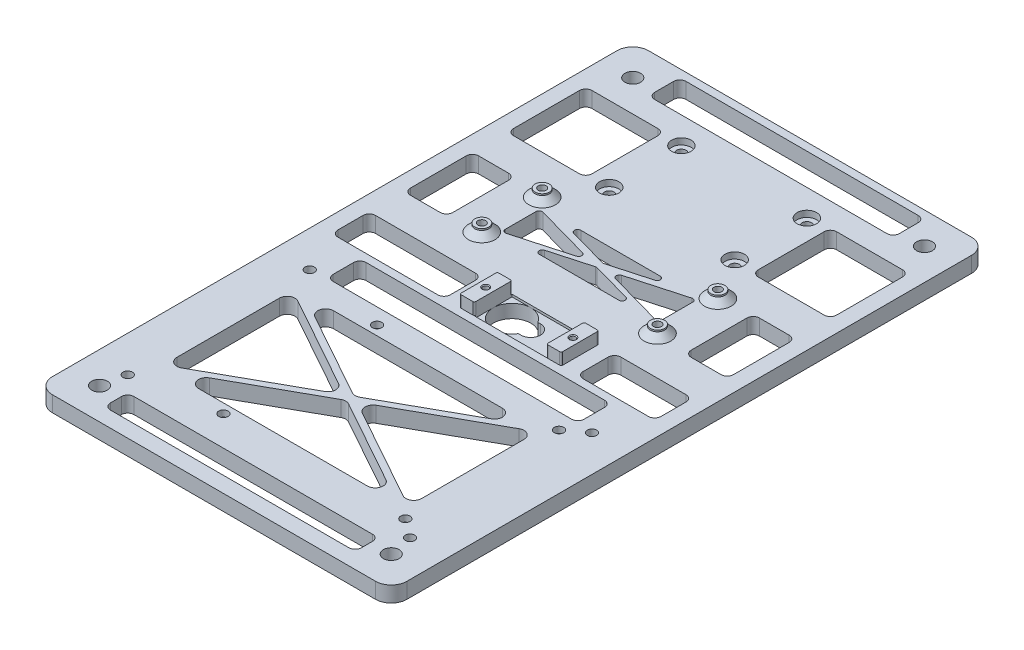
from build123d import *

# Parameters (mm, degrees)
SKETCH1_W           = 113
SKETCH1_H           = 190
SKETCH1_R           = 2.5
BOSS_EXTRUDE1_DEPTH = 5
FILLET1_R           = 5
SKETCH2_R           = 1.5
CUT_EXTRUDE1_DEPTH  = 10
SKETCH3_R           = 1.5
CUT_EXTRUDE2_DEPTH  = 10
CUT_EXTRUDE4_DEPTH  = 10
CUT_EXTRUDE16_DEPTH = 111.644701635
SKETCH22_W          = 23
SKETCH22_H          = 12
CUT_EXTRUDE17_DEPTH = 0.75
SKETCH23_W          = 4.675
SKETCH23_H          = 12
SKETCH23_R          = 0.875
BOSS_EXTRUDE5_DEPTH = 3.75
SKETCH24_R          = 0.875
CUT_EXTRUDE18_DEPTH = 1.5
SKETCH12_W          = 25
SKETCH12_H          = 25
CUT_EXTRUDE9_DEPTH  = 111.644701635
CUT_EXTRUDE11_REACH = 112.645
SKETCH15_W          = 35.825
SKETCH15_H          = 12
SKETCH15_W_2        = 24.825
FILLET3_R           = 2
CUT_EXTRUDE12_REACH = 112.877
SKETCH16_R          = 1.25
CUT_EXTRUDE13_REACH = 112.645
CUT_EXTRUDE14_DEPTH = 111.644701635
SKETCH19_R          = 2.25
SKETCH19_R_2        = 1.25
BOSS_EXTRUDE4_DEPTH = 2.5
CHAMFER1_SIZE       = 2
SKETCH20_R          = 2.5
CUT_EXTRUDE15_DEPTH = 3
FILLET4_R           = 0.5
CHAMFER2_SIZE       = 0.25
SKETCH26_R          = 1.5
CUT_EXTRUDE19_DEPTH = 111.644701635
SKETCH27_R          = 3.1
CUT_EXTRUDE20_DEPTH = 2


with BuildPart() as part:
    # Sketch1 → Boss-Extrude1 (new body)
    with BuildSketch(Plane(origin=(0, 0, 0), x_dir=(1, 0, 0), z_dir=(0, 1, 0))):
        Rectangle(SKETCH1_W, SKETCH1_H)
        with Locations(Location((46.5, 85, 0), (0, 0, 270))):
            Circle(SKETCH1_R, mode=Mode.SUBTRACT)
        with Locations(Location((-46.5, 85, 0), (0, 0, 270))):
            Circle(SKETCH1_R, mode=Mode.SUBTRACT)
        with Locations(Location((-46.5, -85, 0), (0, 0, 270))):
            Circle(SKETCH1_R, mode=Mode.SUBTRACT)
        with Locations(Location((46.5, -85, 0), (0, 0, 270))):
            Circle(SKETCH1_R, mode=Mode.SUBTRACT)
    extrude(amount=BOSS_EXTRUDE1_DEPTH)

    # Fillet1
    fillet1_edges = [part.edges().sort_by_distance(p)[0] for p in [
        (-56.5, 2.5, 95),
        (-56.5, 2.5, -95),
        (56.5, 2.5, -95),
        (56.5, 2.5, 95),
    ]]
    fillet(fillet1_edges, radius=FILLET1_R)

    # Sketch2 → Cut-Extrude1 (cut)
    with BuildSketch(Plane(origin=(0, 5, 0), x_dir=(1, 0, 0), z_dir=(0, 1, 0))):
        with Locations(Location((39, -24, 0), (0, 0, 270))):
            Circle(SKETCH2_R)
        with Locations(Location((39, -73, 0), (0, 0, 270))):
            Circle(SKETCH2_R)
        with Locations(Location((-19, -24, 0), (0, 0, 270))):
            Circle(SKETCH2_R)
        with Locations(Location((-19, -73, 0), (0, 0, 270))):
            Circle(SKETCH2_R)
    extrude(amount=-CUT_EXTRUDE1_DEPTH, mode=Mode.SUBTRACT)

    # Sketch3 → Cut-Extrude2 (cut)
    with BuildSketch(Plane(origin=(0, 5, 0), x_dir=(1, 0, 0), z_dir=(0, 1, 0))):
        with Locations(Location((45, -19.5, 0), (0, 0, 270))):
            Circle(SKETCH3_R)
        with Locations(Location((45, -77.5, 0), (0, 0, 270))):
            Circle(SKETCH3_R)
        with Locations(Location((-45, -19.5, 0), (0, 0, 270))):
            Circle(SKETCH3_R)
        with Locations(Location((-45, -77.5, 0), (0, 0, 270))):
            Circle(SKETCH3_R)
    extrude(amount=-CUT_EXTRUDE2_DEPTH, mode=Mode.SUBTRACT)

    # Sketch5 → Cut-Extrude4 (cut)
    with BuildSketch(Plane(origin=(0, 5, 0), x_dir=(1, 0, 0), z_dir=(0, 1, 0))):
        with BuildLine():
            Line((-38, -90), (38, -90))
            ThreePointArc((38, -90), (39.414213562, -89.414213562), (40, -88))
            Line((40, -88), (40, -84.5))
            ThreePointArc((40, -84.5), (39.414213562, -83.085786438), (38, -82.5))
            Line((38, -82.5), (-38, -82.5))
            ThreePointArc((-38, -82.5), (-39.414213562, -83.085786438), (-40, -84.5))
            Line((-40, -84.5), (-40, -88))
            ThreePointArc((-40, -88), (-39.414213562, -89.414213562), (-38, -90))
        make_face()
    extrude(amount=-CUT_EXTRUDE4_DEPTH, mode=Mode.SUBTRACT)

    # Sketch21 → Cut-Extrude16 (cut, through all)
    with BuildSketch(Plane(origin=(0, 5, 0), x_dir=(1, 0, 0), z_dir=(0, 1, 0))):
        with BuildLine():
            Line((5.975, -3.125), (5.121950312, -3.125))
            ThreePointArc((5.121950312, -3.125), (-6, 0), (5.121950312, 3.125))
            Line((5.121950312, 3.125), (5.975, 3.125))
            ThreePointArc((5.975, 3.125), (9.1, 0), (5.975, -3.125))
        make_face()
    extrude(amount=-CUT_EXTRUDE16_DEPTH, mode=Mode.SUBTRACT)

    # Sketch22 → Cut-Extrude17 (cut)
    with BuildSketch(Plane(origin=(0, 5, 0), x_dir=(1, 0, 0), z_dir=(0, 1, 0))):
        with Locations((5.5, 0)):
            Rectangle(SKETCH22_W, SKETCH22_H)
    extrude(amount=-CUT_EXTRUDE17_DEPTH, mode=Mode.SUBTRACT)

    # Sketch23 → Boss-Extrude5 (add)
    with BuildSketch(Plane(origin=(0, 5, 0), x_dir=(1, 0, 0), z_dir=(0, 1, 0))):
        with Locations((-8.3375, 0)):
            Rectangle(SKETCH23_W, SKETCH23_H)
        with Locations(Location((-8.4, 0, 0), (0, 0, 270))):
            Circle(SKETCH23_R, mode=Mode.SUBTRACT)
        with Locations((19.3375, 0)):
            Rectangle(SKETCH23_W, SKETCH23_H)
        with Locations(Location((19.4, 0, 0), (0, 0, 90))):
            Circle(SKETCH23_R, mode=Mode.SUBTRACT)
    extrude(amount=BOSS_EXTRUDE5_DEPTH)

    # Sketch24 → Cut-Extrude18 (cut)
    with BuildSketch(Plane(origin=(0, 5, 0), x_dir=(1, 0, 0), z_dir=(0, 1, 0))):
        with Locations(Location((19.4, 0, 0), (0, 0, 90))):
            Circle(SKETCH24_R)
        with Locations(Location((-8.4, 0, 0), (0, 0, 270))):
            Circle(SKETCH24_R)
    extrude(amount=-CUT_EXTRUDE18_DEPTH, mode=Mode.SUBTRACT)

    # Sketch12 → Cut-Extrude9 (cut, through all)
    with BuildSketch(Plane(origin=(0, 5, 0), x_dir=(1, 0, 0), z_dir=(0, 1, 0))):
        with Locations((-39, 62.5)):
            Rectangle(SKETCH12_W, SKETCH12_H)
        with Locations((39, 62.5)):
            Rectangle(SKETCH12_W, SKETCH12_H)
    extrude(amount=-CUT_EXTRUDE9_DEPTH, mode=Mode.SUBTRACT)

    # Sketch15 → Cut-Extrude11 (cut, up to next)
    with BuildSketch(Plane(origin=(0, 5, 0), x_dir=(1, 0, 0), z_dir=(0, 1, 0)), mode=Mode.PRIVATE) as cut_extrude11_sk1:
        with Locations((-33.5875, 0)):
            Rectangle(SKETCH15_W, SKETCH15_H)
    cut_extrude11_tool1 = extrude(cut_extrude11_sk1.sketch, amount=-CUT_EXTRUDE11_REACH, mode=Mode.PRIVATE) & part.part
    # Sketch15 → Cut-Extrude11 (cut, up to next)
    with BuildSketch(Plane(origin=(0, 5, 0), x_dir=(1, 0, 0), z_dir=(0, 1, 0)), mode=Mode.PRIVATE) as cut_extrude11_sk2:
        with Locations((39.0875, 0)):
            Rectangle(SKETCH15_W_2, SKETCH15_H)
    cut_extrude11_tool2 = extrude(cut_extrude11_sk2.sketch, amount=-CUT_EXTRUDE11_REACH, mode=Mode.PRIVATE) & part.part
    add(cut_extrude11_tool1.solids().sort_by_distance((-33.5875, 5, 0))[0], mode=Mode.SUBTRACT)
    add(cut_extrude11_tool2.solids().sort_by_distance((39.0875, 5, 0))[0], mode=Mode.SUBTRACT)

    # Fillet3
    fillet3_edges = [part.edges().sort_by_distance(p)[0] for p in [
        (-51.5, 2.5, -50),
        (-51.5, 2.5, -75),
        (-26.5, 2.5, -75),
        (-26.5, 2.5, -50),
        (26.5, 2.5, -75),
        (51.5, 2.5, -75),
        (51.5, 2.5, -50),
        (26.5, 2.5, -50),
        (-51.5, 2.5, 6),
        (-51.5, 2.5, -6),
        (-15.675, 2.5, -6),
        (-15.675, 2.5, 6),
        (26.675, 2.5, 6),
        (26.675, 2.5, -6),
        (51.5, 2.5, -6),
        (51.5, 2.5, 6),
    ]]
    fillet(fillet3_edges, radius=FILLET3_R)

    # Sketch16 → Cut-Extrude12 (cut, up to next)
    with BuildSketch(Plane.XZ, mode=Mode.PRIVATE) as cut_extrude12_sk1:
        with Locations(Location((-28, -18.375, 0), (0, 0, 270))):
            Circle(SKETCH16_R)
    cut_extrude12_tool1 = extrude(cut_extrude12_sk1.sketch, amount=-CUT_EXTRUDE12_REACH, mode=Mode.PRIVATE) & part.part
    # Sketch16 → Cut-Extrude12 (cut, up to next)
    with BuildSketch(Plane.XZ, mode=Mode.PRIVATE) as cut_extrude12_sk2:
        with Locations(Location((28, -18.375, 0), (0, 0, 270))):
            Circle(SKETCH16_R)
    cut_extrude12_tool2 = extrude(cut_extrude12_sk2.sketch, amount=-CUT_EXTRUDE12_REACH, mode=Mode.PRIVATE) & part.part
    # Sketch16 → Cut-Extrude12 (cut, up to next)
    with BuildSketch(Plane.XZ, mode=Mode.PRIVATE) as cut_extrude12_sk3:
        with Locations(Location((28, -37.625, 0), (0, 0, 270))):
            Circle(SKETCH16_R)
    cut_extrude12_tool3 = extrude(cut_extrude12_sk3.sketch, amount=-CUT_EXTRUDE12_REACH, mode=Mode.PRIVATE) & part.part
    # Sketch16 → Cut-Extrude12 (cut, up to next)
    with BuildSketch(Plane.XZ, mode=Mode.PRIVATE) as cut_extrude12_sk4:
        with Locations(Location((-28, -37.625, 0), (0, 0, 270))):
            Circle(SKETCH16_R)
    cut_extrude12_tool4 = extrude(cut_extrude12_sk4.sketch, amount=-CUT_EXTRUDE12_REACH, mode=Mode.PRIVATE) & part.part
    # Sketch16 → Cut-Extrude12 (cut, up to next)
    with BuildSketch(Plane.XZ, mode=Mode.PRIVATE) as cut_extrude12_sk5:
        with BuildLine():
            Line((-42, 64.8228648), (-42, 32.1771352))
            ThreePointArc((-42, 32.1771352), (-40.766661958, 30.021777345), (-38.283546013, 29.993047359))
            Line((-38.283546013, 29.993047359), (-8.976584213, 46.315912159))
            ThreePointArc((-8.976584213, 46.315912159), (-7.6930382, 48.5), (-8.976584213, 50.684087841))
            Line((-8.976584213, 50.684087841), (-38.283546013, 67.006952641))
            ThreePointArc((-38.283546013, 67.006952641), (-40.766661958, 66.978222655), (-42, 64.8228648))
        make_face()
    cut_extrude12_tool5 = extrude(cut_extrude12_sk5.sketch, amount=-CUT_EXTRUDE12_REACH, mode=Mode.PRIVATE) & part.part
    # Sketch16 → Cut-Extrude12 (cut, up to next)
    with BuildSketch(Plane.XZ, mode=Mode.PRIVATE) as cut_extrude12_sk6:
        with BuildLine():
            Line((-31.13705215, 31.684087841), (-4.216453987, 46.677838717))
            ThreePointArc((-4.216453987, 46.677838717), (-3, 46.993750876), (-1.783546013, 46.677838717))
            Line((-1.783546013, 46.677838717), (25.13705215, 31.684087841))
            ThreePointArc((25.13705215, 31.684087841), (26.340331578, 28.871597105), (23.920598163, 27))
            Line((23.920598163, 27), (-29.920598163, 27))
            ThreePointArc((-29.920598163, 27), (-32.340331578, 28.871597105), (-31.13705215, 31.684087841))
        make_face()
    cut_extrude12_tool6 = extrude(cut_extrude12_sk6.sketch, amount=-CUT_EXTRUDE12_REACH, mode=Mode.PRIVATE) & part.part
    # Sketch16 → Cut-Extrude12 (cut, up to next)
    with BuildSketch(Plane.XZ, mode=Mode.PRIVATE) as cut_extrude12_sk7:
        with BuildLine():
            Line((32.283546013, 29.993047359), (2.976584213, 46.315912159))
            ThreePointArc((2.976584213, 46.315912159), (1.6930382, 48.5), (2.976584213, 50.684087841))
            Line((2.976584213, 50.684087841), (32.283546013, 67.006952641))
            ThreePointArc((32.283546013, 67.006952641), (34.766661958, 66.978222655), (36, 64.8228648))
            Line((36, 64.8228648), (36, 32.1771352))
            ThreePointArc((36, 32.1771352), (34.766661958, 30.021777345), (32.283546013, 29.993047359))
        make_face()
    cut_extrude12_tool7 = extrude(cut_extrude12_sk7.sketch, amount=-CUT_EXTRUDE12_REACH, mode=Mode.PRIVATE) & part.part
    # Sketch16 → Cut-Extrude12 (cut, up to next)
    with BuildSketch(Plane.XZ, mode=Mode.PRIVATE) as cut_extrude12_sk8:
        with BuildLine():
            Line((-1.783546013, 50.322161283), (25.13705215, 65.315912159))
            ThreePointArc((25.13705215, 65.315912159), (26.340331578, 68.128402895), (23.920598163, 70))
            Line((23.920598163, 70), (-29.920598163, 70))
            ThreePointArc((-29.920598163, 70), (-32.340331578, 68.128402895), (-31.13705215, 65.315912159))
            Line((-31.13705215, 65.315912159), (-4.216453987, 50.322161283))
            ThreePointArc((-4.216453987, 50.322161283), (-3, 50.006249124), (-1.783546013, 50.322161283))
        make_face()
    cut_extrude12_tool8 = extrude(cut_extrude12_sk8.sketch, amount=-CUT_EXTRUDE12_REACH, mode=Mode.PRIVATE) & part.part
    # Sketch16 → Cut-Extrude12 (cut, up to next)
    with BuildSketch(Plane.XZ, mode=Mode.PRIVATE) as cut_extrude12_sk9:
        with BuildLine():
            Line((-37, -82.5), (37, -82.5))
            ThreePointArc((37, -82.5), (38.414213562, -83.085786438), (39, -84.5))
            Line((39, -84.5), (39, -90.5))
            ThreePointArc((39, -90.5), (38.414213562, -91.914213562), (37, -92.5))
            Line((37, -92.5), (-37, -92.5))
            ThreePointArc((-37, -92.5), (-38.414213562, -91.914213562), (-39, -90.5))
            Line((-39, -90.5), (-39, -84.5))
            ThreePointArc((-39, -84.5), (-38.414213562, -83.085786438), (-37, -82.5))
        make_face()
    cut_extrude12_tool9 = extrude(cut_extrude12_sk9.sketch, amount=-CUT_EXTRUDE12_REACH, mode=Mode.PRIVATE) & part.part
    add(cut_extrude12_tool1.solids().sort_by_distance((-28, 0, -18.375))[0], mode=Mode.SUBTRACT)
    add(cut_extrude12_tool2.solids().sort_by_distance((28, 0, -18.375))[0], mode=Mode.SUBTRACT)
    add(cut_extrude12_tool3.solids().sort_by_distance((28, 0, -37.625))[0], mode=Mode.SUBTRACT)
    add(cut_extrude12_tool4.solids().sort_by_distance((-28, 0, -37.625))[0], mode=Mode.SUBTRACT)
    add(cut_extrude12_tool5.solids().sort_by_distance((-29.697812, 0, 48.5))[0], mode=Mode.SUBTRACT)
    add(cut_extrude12_tool6.solids().sort_by_distance((-3, 0, 34.022847))[0], mode=Mode.SUBTRACT)
    add(cut_extrude12_tool7.solids().sort_by_distance((23.697812, 0, 48.5))[0], mode=Mode.SUBTRACT)
    add(cut_extrude12_tool8.solids().sort_by_distance((-3, 0, 62.977153))[0], mode=Mode.SUBTRACT)
    add(cut_extrude12_tool9.solids().sort_by_distance((0, 0, -87.5))[0], mode=Mode.SUBTRACT)

    # Sketch17 → Cut-Extrude13 (cut, up to next)
    with BuildSketch(Plane(origin=(0, 5, 0), x_dir=(1, 0, 0), z_dir=(0, 1, 0)), mode=Mode.PRIVATE) as cut_extrude13_sk1:
        with BuildLine():
            Line((-40, 38.875), (-49.5, 38.875))
            ThreePointArc((-49.5, 38.875), (-50.914213562, 38.289213562), (-51.5, 36.875))
            Line((-51.5, 36.875), (-51.5, 19.125))
            ThreePointArc((-51.5, 19.125), (-50.914213562, 17.710786438), (-49.5, 17.125))
            Line((-49.5, 17.125), (-40, 17.125))
            ThreePointArc((-40, 17.125), (-38.585786438, 17.710786438), (-38, 19.125))
            Line((-38, 19.125), (-38, 36.875))
            ThreePointArc((-38, 36.875), (-38.585786438, 38.289213562), (-40, 38.875))
        make_face()
    cut_extrude13_tool1 = extrude(cut_extrude13_sk1.sketch, amount=-CUT_EXTRUDE13_REACH, mode=Mode.PRIVATE) & part.part
    # Sketch17 → Cut-Extrude13 (cut, up to next)
    with BuildSketch(Plane(origin=(0, 5, 0), x_dir=(1, 0, 0), z_dir=(0, 1, 0)), mode=Mode.PRIVATE) as cut_extrude13_sk2:
        with BuildLine():
            Line((40, 17.125), (49.5, 17.125))
            ThreePointArc((49.5, 17.125), (50.914213562, 17.710786438), (51.5, 19.125))
            Line((51.5, 19.125), (51.5, 36.875))
            ThreePointArc((51.5, 36.875), (50.914213562, 38.289213562), (49.5, 38.875))
            Line((49.5, 38.875), (40, 38.875))
            ThreePointArc((40, 38.875), (38.585786438, 38.289213562), (38, 36.875))
            Line((38, 36.875), (38, 19.125))
            ThreePointArc((38, 19.125), (38.585786438, 17.710786438), (40, 17.125))
        make_face()
    cut_extrude13_tool2 = extrude(cut_extrude13_sk2.sketch, amount=-CUT_EXTRUDE13_REACH, mode=Mode.PRIVATE) & part.part
    add(cut_extrude13_tool1.solids().sort_by_distance((-44.75, 5, -28))[0], mode=Mode.SUBTRACT)
    add(cut_extrude13_tool2.solids().sort_by_distance((44.75, 5, -28))[0], mode=Mode.SUBTRACT)

    # Sketch18 → Cut-Extrude14 (cut, through all)
    with BuildSketch(Plane(origin=(0, 5, 0), x_dir=(1, 0, 0), z_dir=(0, 1, 0))):
        with BuildLine():
            Line((-25, 32.629278458), (-25, 22.851570568))
            ThreePointArc((-25, 22.851570568), (-24.60452273, 22.054982677), (-23.730895463, 21.888459594))
            Line((-23.730895463, 21.888459594), (-6.233944503, 26.777313539))
            ThreePointArc((-6.233944503, 26.777313539), (-5.50304904, 27.740424513), (-6.233944503, 28.703535487))
            Line((-6.233944503, 28.703535487), (-23.730895463, 33.592389432))
            ThreePointArc((-23.730895463, 33.592389432), (-24.60452273, 33.425866349), (-25, 32.629278458))
        make_face()
        with BuildLine():
            Line((-12.699522902, 34.625), (12.699522902, 34.625))
            ThreePointArc((12.699522902, 34.625), (13.690257724, 33.760810578), (12.968627439, 32.661889026))
            Line((12.968627439, 32.661889026), (0.269104537, 29.113492921))
            ThreePointArc((0.269104537, 29.113492921), (0, 29.076603895), (-0.269104537, 29.113492921))
            Line((-0.269104537, 29.113492921), (-12.968627439, 32.661889026))
            ThreePointArc((-12.968627439, 32.661889026), (-13.690257724, 33.760810578), (-12.699522902, 34.625))
        make_face()
        with BuildLine():
            Line((23.730895463, 21.888459594), (6.233944503, 26.777313539))
            ThreePointArc((6.233944503, 26.777313539), (5.50304904, 27.740424513), (6.233944503, 28.703535487))
            Line((6.233944503, 28.703535487), (23.730895463, 33.592389432))
            ThreePointArc((23.730895463, 33.592389432), (24.60452273, 33.425866349), (25, 32.629278458))
            Line((25, 32.629278458), (25, 22.851570568))
            ThreePointArc((25, 22.851570568), (24.60452273, 22.054982677), (23.730895463, 21.888459594))
        make_face()
        with BuildLine():
            Line((12.968627439, 23.338110974), (0.269104537, 26.886507079))
            ThreePointArc((0.269104537, 26.886507079), (0, 26.923396105), (-0.269104537, 26.886507079))
            Line((-0.269104537, 26.886507079), (-12.968627439, 23.338110974))
            ThreePointArc((-12.968627439, 23.338110974), (-13.690257724, 22.239189422), (-12.699522902, 21.375))
            Line((-12.699522902, 21.375), (12.699522902, 21.375))
            ThreePointArc((12.699522902, 21.375), (13.690257724, 22.239189422), (12.968627439, 23.338110974))
        make_face()
        with BuildLine():
            Line((-38, -8.5), (38, -8.5))
            ThreePointArc((38, -8.5), (39.414213562, -9.085786438), (40, -10.5))
            Line((40, -10.5), (40, -17))
            ThreePointArc((40, -17), (39.414213562, -18.414213562), (38, -19))
            Line((38, -19), (-38, -19))
            ThreePointArc((-38, -19), (-39.414213562, -18.414213562), (-40, -17))
            Line((-40, -17), (-40, -10.5))
            ThreePointArc((-40, -10.5), (-39.414213562, -9.085786438), (-38, -8.5))
        make_face()
    extrude(amount=-CUT_EXTRUDE14_DEPTH, mode=Mode.SUBTRACT)

    # Sketch19 → Boss-Extrude4 (add)
    with BuildSketch(Plane(origin=(0, 5, 0), x_dir=(1, 0, 0), z_dir=(0, 1, 0))):
        with Locations(Location((-28, 37.625, 0), (0, 0, 270))):
            Circle(SKETCH19_R)
        with Locations(Location((-28, 37.625, 0), (0, 0, 90))):
            Circle(SKETCH19_R_2, mode=Mode.SUBTRACT)
        with Locations(Location((-28, 18.375, 0), (0, 0, 270))):
            Circle(SKETCH19_R)
        with Locations(Location((-28, 18.375, 0), (0, 0, 90))):
            Circle(SKETCH19_R_2, mode=Mode.SUBTRACT)
        with Locations(Location((28, 37.625, 0), (0, 0, 270))):
            Circle(SKETCH19_R)
        with Locations(Location((28, 37.625, 0), (0, 0, 90))):
            Circle(SKETCH19_R_2, mode=Mode.SUBTRACT)
        with Locations(Location((28, 18.375, 0), (0, 0, 270))):
            Circle(SKETCH19_R)
        with Locations(Location((28, 18.375, 0), (0, 0, 90))):
            Circle(SKETCH19_R_2, mode=Mode.SUBTRACT)
    extrude(amount=BOSS_EXTRUDE4_DEPTH)

    # Chamfer1
    chamfer1_edges = [part.edges().sort_by_distance(p)[0] for p in [
        (-28, 5, -39.875),
        (-28, 5, -20.625),
        (28, 5, -39.875),
        (28, 5, -20.625),
    ]]
    chamfer(chamfer1_edges, length=CHAMFER1_SIZE)

    # Sketch20 → Cut-Extrude15 (cut)
    with BuildSketch(Plane.XZ):
        with Locations(Location((-19, 73, 0), (0, 0, 270))):
            Circle(SKETCH20_R)
        with Locations(Location((-19, 24, 0), (0, 0, 270))):
            Circle(SKETCH20_R)
        with Locations(Location((39, 24, 0), (0, 0, 270))):
            Circle(SKETCH20_R)
        with Locations(Location((39, 73, 0), (0, 0, 270))):
            Circle(SKETCH20_R)
    extrude(amount=-CUT_EXTRUDE15_DEPTH, mode=Mode.SUBTRACT)

    # Fillet4
    fillet4_edges = [part.edges().sort_by_distance(p)[0] for p in [
        (-6, 6.875, -6),
        (-10.675, 6.875, -6),
        (-10.675, 6.875, 6),
        (-6, 6.875, 6),
        (17, 6.875, -6),
        (17, 6.875, 6),
        (21.675, 6.875, 6),
        (21.675, 6.875, -6),
    ]]
    fillet(fillet4_edges, radius=FILLET4_R)

    # Chamfer2
    chamfer2_edges = [part.edges().sort_by_distance(p)[0] for p in [
        (-8.4, 8.75, -0.875),
        (19.4, 8.75, 0.875),
    ]]
    chamfer(chamfer2_edges, length=CHAMFER2_SIZE)

    # Sketch26 → Cut-Extrude19 (cut, through all)
    with BuildSketch(Plane(origin=(0, 5, 0), x_dir=(1, 0, 0), z_dir=(0, 1, 0))):
        with Locations(Location((-20, 74, 0), (0, 0, 270))):
            Circle(SKETCH26_R)
        with Locations(Location((-20, 51, 0), (0, 0, 270))):
            Circle(SKETCH26_R)
        with Locations(Location((20, 74, 0), (0, 0, 270))):
            Circle(SKETCH26_R)
        with Locations(Location((20, 51, 0), (0, 0, 270))):
            Circle(SKETCH26_R)
    extrude(amount=-CUT_EXTRUDE19_DEPTH, mode=Mode.SUBTRACT)

    # Sketch27 → Cut-Extrude20 (cut)
    with BuildSketch(Plane(origin=(0, 5, 0), x_dir=(1, 0, 0), z_dir=(0, 1, 0))):
        with Locations(Location((-20, 74, 0), (0, 0, 270))):
            Circle(SKETCH27_R)
        with Locations(Location((-20, 51, 0), (0, 0, 270))):
            Circle(SKETCH27_R)
        with Locations(Location((20, 51, 0), (0, 0, 270))):
            Circle(SKETCH27_R)
        with Locations(Location((20, 74, 0), (0, 0, 270))):
            Circle(SKETCH27_R)
    extrude(amount=-CUT_EXTRUDE20_DEPTH, mode=Mode.SUBTRACT)


solid = part.part
